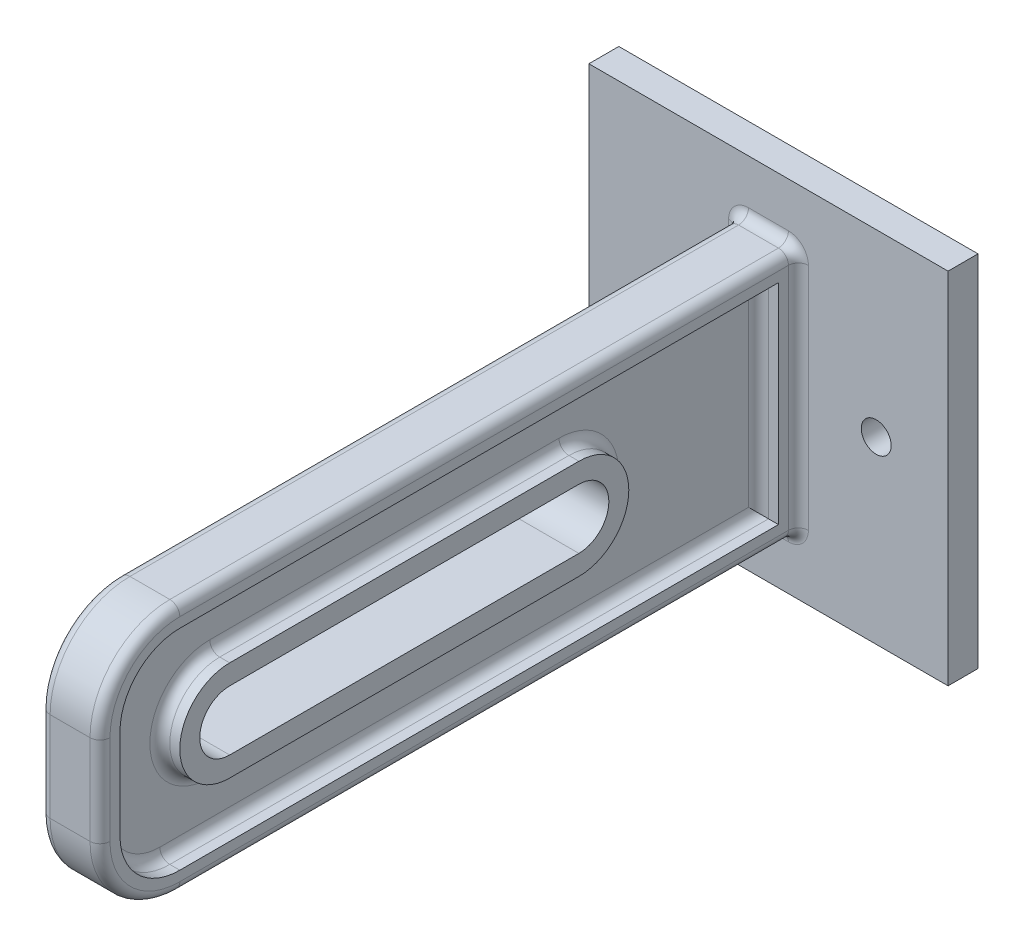
from build123d import *

# Parameters (mm, degrees)
SKETCH1_W               = 36
SKETCH1_H               = 36
BOSS_EXTRUDE1_DEPTH     = 3
SKETCH2_R               = 1.5
CUT_EXTRUDE1_DEPTH      = 4
SKETCH3_W               = 6
SKETCH3_H               = 25
BOSS_EXTRUDE2_DEPTH     = 70
CUT_EXTRUDE2_DEPTH      = 41
CUT_EXTRUDE2_DEPTH_BACK = 19
FILLET1_R               = 8
CUT_EXTRUDE3_DEPTH      = 2
FILLET2_R               = 1


with BuildPart() as part:
    # Sketch1 → Boss-Extrude1 (new body)
    with BuildSketch(Plane.XY):
        Rectangle(SKETCH1_W, SKETCH1_H)
    extrude(amount=BOSS_EXTRUDE1_DEPTH)

    # Sketch2 → Cut-Extrude1 (cut, through all)
    with BuildSketch(Plane.XY.offset(3)):
        with Locations((10.79827875, 0)):
            Circle(SKETCH2_R)
        with Locations((-9.20172125, 0)):
            Circle(SKETCH2_R)
    extrude(amount=-CUT_EXTRUDE1_DEPTH, mode=Mode.SUBTRACT)

    # Sketch3 → Boss-Extrude2 (add)
    with BuildSketch(Plane.XY.offset(3)):
        Rectangle(SKETCH3_W, SKETCH3_H)
    extrude(amount=BOSS_EXTRUDE2_DEPTH)

    # Sketch6 → Cut-Extrude2 (cut, two sides)
    with BuildSketch(Plane(origin=(0, 0, 0), x_dir=(0, 0, -1), z_dir=(1, 0, 0))) as cut_extrude2_sk:
        with BuildLine():
            Line((-25, 3), (-60, 3))
            ThreePointArc((-60, 3), (-63, 0), (-60, -3))
            Line((-60, -3), (-25, -3))
            ThreePointArc((-25, -3), (-22, 0), (-25, 3))
        make_face()
    extrude(amount=CUT_EXTRUDE2_DEPTH, mode=Mode.SUBTRACT)
    extrude(cut_extrude2_sk.sketch, amount=-CUT_EXTRUDE2_DEPTH_BACK, mode=Mode.SUBTRACT)

    # Fillet1
    fillet1_edges = [part.edges().sort_by_distance(p)[0] for p in [
        (0, -12.5, 73),
        (0, 12.5, 73),
    ]]
    fillet(fillet1_edges, radius=FILLET1_R)

    # Sketch7 → Cut-Extrude3 (cut)
    with BuildSketch(Plane.ZY.offset(3)):
        with BuildLine():
            Line((65, 10.5), (5, 10.5))
            Line((5, 10.5), (5, -10.5))
            Line((5, -10.5), (65, -10.5))
            ThreePointArc((65, -10.5), (69.242640687, -8.742640687), (71, -4.5))
            Line((71, -4.5), (71, 4.5))
            ThreePointArc((71, 4.5), (69.242640687, 8.742640687), (65, 10.5))
        make_face()
        with BuildLine():
            Line((60, 5), (25, 5))
            ThreePointArc((25, 5), (20, 0), (25, -5))
            Line((25, -5), (60, -5))
            ThreePointArc((60, -5), (65, 0), (60, 5))
        make_face(mode=Mode.SUBTRACT)
    cut_extrude3 = extrude(amount=-CUT_EXTRUDE3_DEPTH, mode=Mode.SUBTRACT)

    # Mirror1: Cut-Extrude3 across plane
    add(cut_extrude3.mirror(Plane(origin=(0, 0, 0), x_dir=(0, 0, 1), z_dir=(1, 0, 0))), mode=Mode.SUBTRACT)

    # Fillet2
    fillet2_edges = [part.edges().sort_by_distance(p)[0] for p in [
        (1, 8.742640687, 69.242640687),
        (1, 10.5, 35),
        (1, 0, 5),
        (1, -10.5, 35),
        (1, -8.742640687, 69.242640687),
        (1, 0, 71),
        (1, 0, 65),
        (1, 5, 42.5),
        (1, 0, 20),
        (1, -5, 42.5),
        (-3, 0, 3),
        (0, -12.5, 3),
        (3, 0, 3),
        (0, 12.5, 3),
        (-3, 0, 73),
        (3, 0, 73),
        (3, 12.5, 34),
        (3, -12.5, 34),
        (3, 10.156854249, 70.656854249),
        (3, -10.156854249, 70.656854249),
        (-3, -12.5, 34),
        (-3, 12.5, 34),
        (-3, 10.156854249, 70.656854249),
        (-3, -10.156854249, 70.656854249),
        (-1, 8.742640687, 69.242640687),
        (-1, 0, 71),
        (-1, -8.742640687, 69.242640687),
        (-1, -10.5, 35),
        (-1, 0, 5),
        (-1, 10.5, 35),
        (-1, -5, 42.5),
        (-1, 0, 65),
        (-1, 5, 42.5),
        (-1, 0, 20),
    ]]
    fillet(fillet2_edges, radius=FILLET2_R)


solid = part.part
